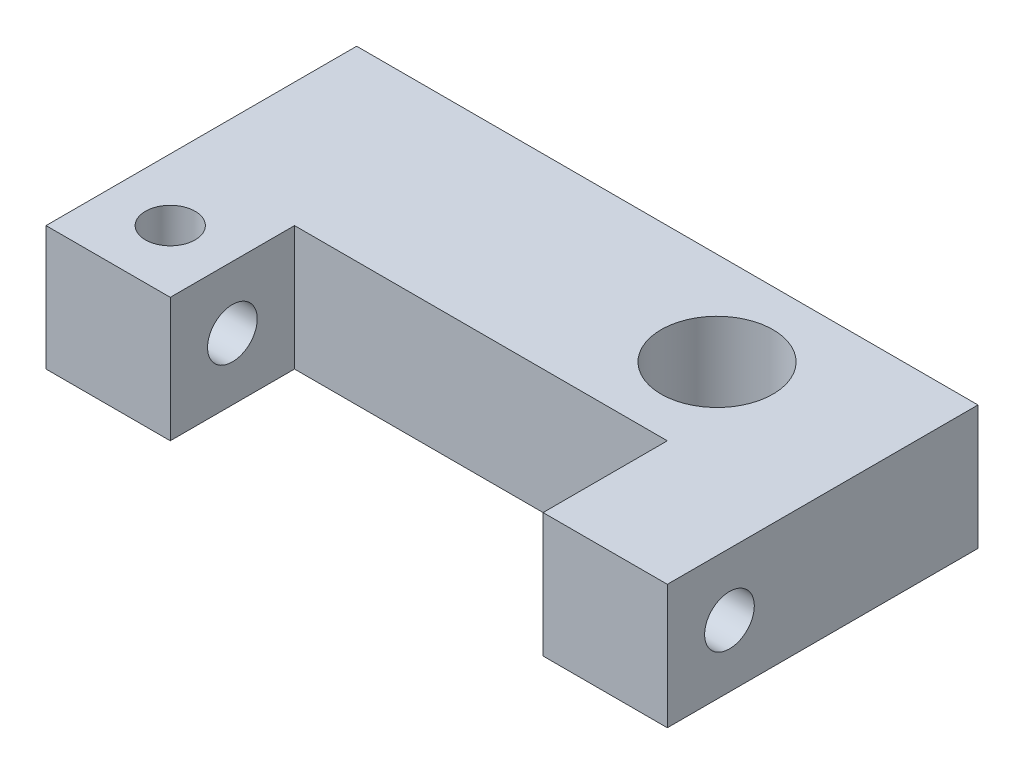
from build123d import *

# Parameters (mm, degrees)
BOSS_EXTRU_1_DEPTH                           = 6
ESQUISSE2_W                                  = 4
ESQUISSE2_H                                  = 4
BOSS_EXTRU_2_DEPTH                           = 4
TROU_POUR_TARAUDAGE_POUR_TROU_TARAUD_M2_D    = 1.6
TROU_POUR_TARAUDAGE_POUR_TROU_TARAUD_2_REACH = 15.115
TROU_POUR_TARAUDAGE_POUR_TROU_TARAUD_2_B_R   = 0.8
D_GAGEMENT_M31_D                             = 3.6


with BuildPart() as part:
    # Esquisse1 → Boss.-Extru.1 (new body)
    with BuildSketch(Plane.XY):
        Polygon((-10, 4), (10, 4), (10, 0), (7, 0), (7, -2), (2.2, -2), (2.2, 0), (-10, 0), align=None)
    extrude(amount=-BOSS_EXTRU_1_DEPTH)

    # Esquisse2 → Boss.-Extru.2 (add)
    with BuildSketch(Plane.XY):
        with Locations((-8, 2)):
            Rectangle(ESQUISSE2_W, ESQUISSE2_H)
        with Locations((8, 2)):
            Rectangle(ESQUISSE2_W, ESQUISSE2_H)
    extrude(amount=BOSS_EXTRU_2_DEPTH)

    # Trou pour taraudage pour trou taraud_ M2 (through all)
    with Locations(Plane(origin=(10, 0, 0), x_dir=(0, 0, -1), z_dir=(1, 0, 0))):
        with Locations((-2, 2)):
            Hole(TROU_POUR_TARAUDAGE_POUR_TROU_TARAUD_M2_D / 2)

    # Trou pour taraudage pour trou taraud 2 b → Trou pour taraudage pour trou taraud 2 (cut, up to next)
    with BuildSketch(Plane(origin=(0, 4, 0), x_dir=(1, 0, 0), z_dir=(0, 1, 0)), mode=Mode.PRIVATE) as trou_pour_taraudage_pour_trou_taraud_2_sk1:
        with Locations((-8, -2)):
            Circle(TROU_POUR_TARAUDAGE_POUR_TROU_TARAUD_2_B_R)
    trou_pour_taraudage_pour_trou_taraud_2_tool1 = extrude(trou_pour_taraudage_pour_trou_taraud_2_sk1.sketch, amount=-TROU_POUR_TARAUDAGE_POUR_TROU_TARAUD_2_REACH, mode=Mode.PRIVATE) & part.part
    add(trou_pour_taraudage_pour_trou_taraud_2_tool1.solids().sort_by_distance((-8, 4, 2))[0], mode=Mode.SUBTRACT)

    # Dégagement M31 (through all)
    with Locations(Plane(origin=(0, 4, 0), x_dir=(1, 0, 0), z_dir=(0, 1, 0))):
        with Locations((4.6, 3)):
            Hole(D_GAGEMENT_M31_D / 2)


solid = part.part
